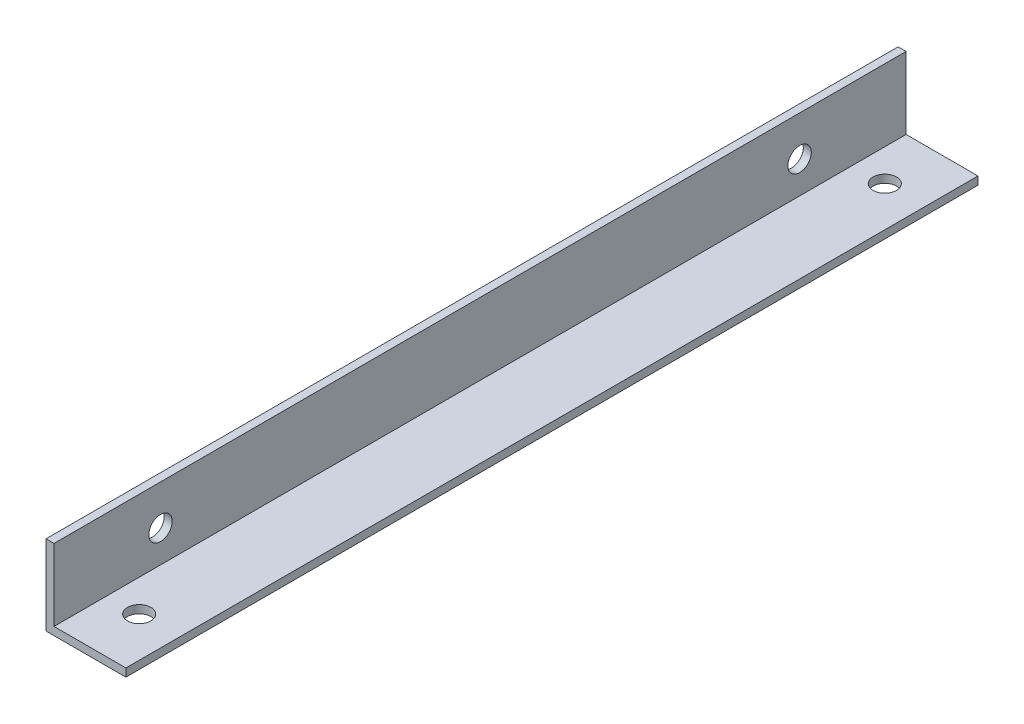
from build123d import *

# Parameters (mm, degrees)
EXTRUDE_1_DEPTH     = 160
SKETCH_2_R          = 2.2
CUT_EXTRUDE_1_DEPTH = 16
SKETCH_3_R          = 2.2
CUT_EXTRUDE_2_DEPTH = 160


with BuildPart() as part:
    # ｽｹｯﾁ1 → ﾎﾞｽ - 押し出し1 (new body)
    with BuildSketch(Plane.XY):
        Polygon((0, 0), (0, 15), (1.5, 15), (1.5, 1.5), (15, 1.5), (15, 0), align=None)
    extrude(amount=EXTRUDE_1_DEPTH)

    # ｽｹｯﾁ2 → ｶｯﾄ - 押し出し1 (cut, through all)
    with BuildSketch(Plane.ZY):
        with Locations((20, 7.5)):
            Circle(SKETCH_2_R)
        with Locations((140, 7.5)):
            Circle(SKETCH_2_R)
    extrude(amount=-CUT_EXTRUDE_1_DEPTH, mode=Mode.SUBTRACT)

    # ｽｹｯﾁ3 → ｶｯﾄ - 押し出し2 (cut)
    with BuildSketch(Plane(origin=(0, 0, 0), x_dir=(-1, 0, 0), z_dir=(0, -1, 0))):
        with Locations((-7.5, -10)):
            Circle(SKETCH_3_R)
        with Locations((-7.5, -150)):
            Circle(SKETCH_3_R)
    extrude(amount=-CUT_EXTRUDE_2_DEPTH, mode=Mode.SUBTRACT)


solid = part.part
